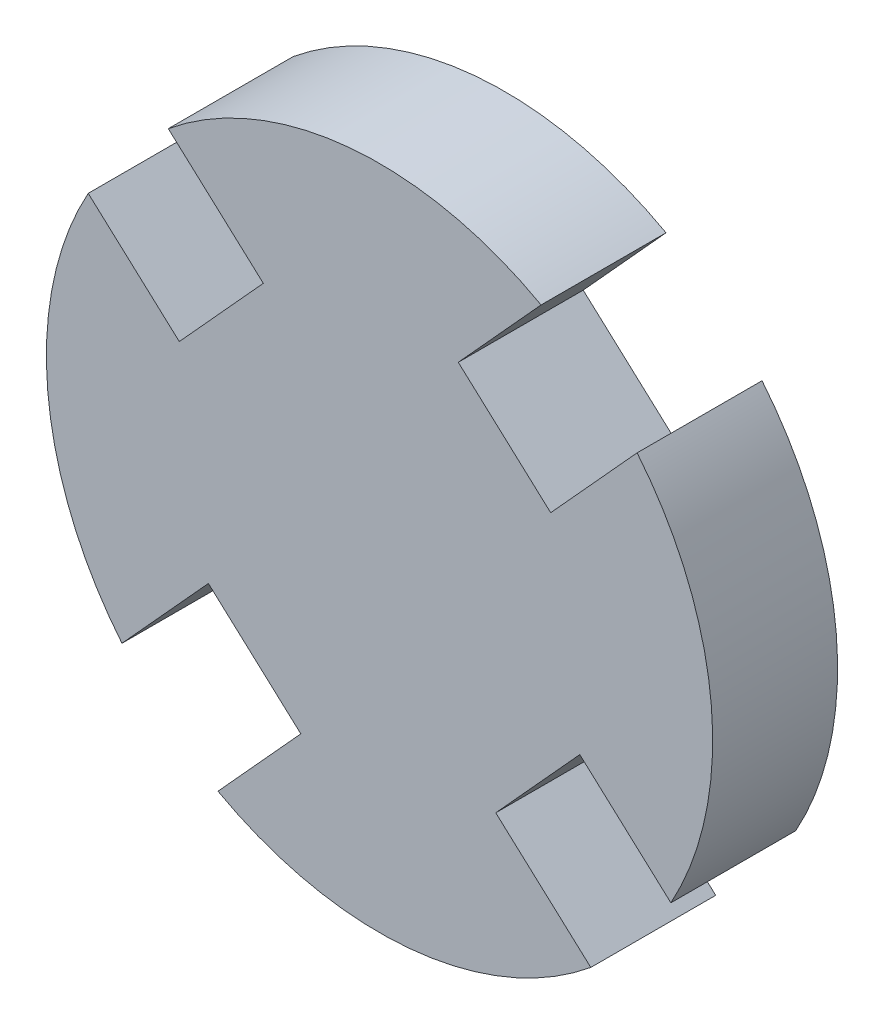
from build123d import *

# Parameters (mm, degrees)
SALIENTE_EXTRUIR3_DEPTH = 3
CROQUIS4_R              = 10
CROQUIS4_R_2            = 8
CORTAR_EXTRUIR4_DEPTH   = 4


with BuildPart() as part:
    # Croquis3 → Saliente-Extruir3 (new body)
    with BuildSketch(Plane.XY):
        with BuildLine():
            Line((-1.890656386, -4.808889521), (-5.254187971, -8.508437504))
            ThreePointArc((-5.254187971, -8.508437504), (0.814446084, -9.966778696), (6.565812029, -7.54255344))
            Line((6.565812029, -7.54255344), (2.790770571, -4.110385176))
            Line((2.790770571, -4.110385176), (4.808889521, -1.890656386))
            Line((4.808889521, -1.890656386), (8.508437504, -5.254187971))
            ThreePointArc((8.508437504, -5.254187971), (9.966778696, 0.814446084), (7.54255344, 6.565812029))
            Line((7.54255344, 6.565812029), (4.110385176, 2.790770571))
            Line((4.110385176, 2.790770571), (1.890656386, 4.808889521))
            Line((1.890656386, 4.808889521), (5.254187971, 8.508437504))
            ThreePointArc((5.254187971, 8.508437504), (-0.814446084, 9.966778696), (-6.565812029, 7.54255344))
            Line((-6.565812029, 7.54255344), (-2.790770571, 4.110385176))
            Line((-2.790770571, 4.110385176), (-4.808889521, 1.890656386))
            Line((-4.808889521, 1.890656386), (-8.508437504, 5.254187971))
            ThreePointArc((-8.508437504, 5.254187971), (-9.966778696, -0.814446084), (-7.54255344, -6.565812029))
            Line((-7.54255344, -6.565812029), (-4.110385176, -2.790770571))
            Line((-4.110385176, -2.790770571), (-1.890656386, -4.808889521))
        make_face()
    extrude(amount=SALIENTE_EXTRUIR3_DEPTH)

    # Croquis4 → Cortar-Extruir4 (cut, through all)
    with BuildSketch(Plane.XY.offset(3)):
        Circle(CROQUIS4_R)
        Circle(CROQUIS4_R_2, mode=Mode.SUBTRACT)
    extrude(amount=-CORTAR_EXTRUIR4_DEPTH, mode=Mode.SUBTRACT)


solid = part.part
